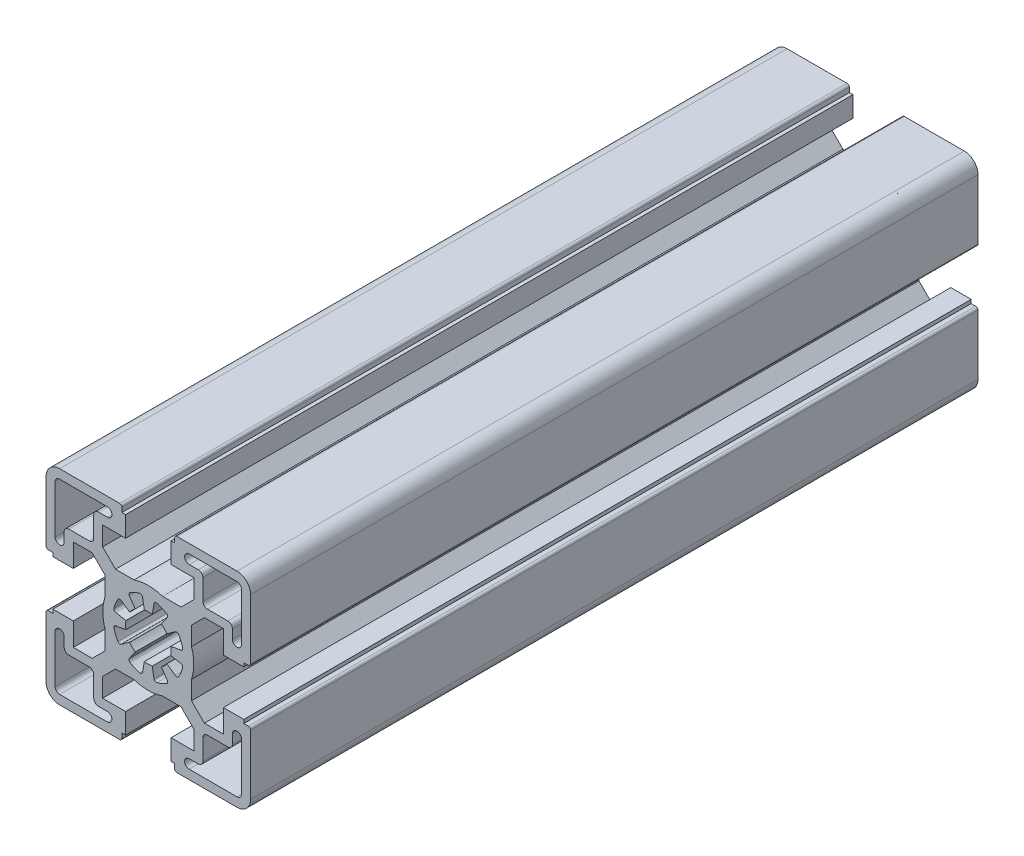
from build123d import *

# Parameters (mm, degrees)
BASE_EXTRUDE_DEPTH = 160


with BuildPart() as part:
    # Sketch1 → Base-Extrude (new body)
    with BuildSketch(Plane.XY):
        with BuildLine():
            Line((-4.99999574, -16.499883971), (-4.99999574, -20.99990968))
            Line((-4.99999574, -20.99990968), (-5.80004044, -20.99990968))
            Line((-5.80004044, -20.99990968), (-5.80004044, -21.999970054))
            ThreePointArc((-5.80004044, -21.999970054), (-5.946487232, -22.353523887), (-6.300041066, -22.49997068))
            Line((-6.300041066, -22.49997068), (-19.500014911, -22.49997068))
            ThreePointArc((-19.500014911, -22.49997068), (-21.62133367, -21.62129168), (-22.50001267, -19.499972921))
            Line((-22.50001267, -19.499972921), (-22.50001267, -6.299929564))
            ThreePointArc((-22.50001267, -6.299929564), (-22.353566213, -5.946376541), (-22.00001319, -5.799930084))
            Line((-22.00001319, -5.799930084), (-21.000012806, -5.799930084))
            Line((-21.000012806, -5.799930084), (-21.000012806, -4.999940084))
            Line((-21.000012806, -4.999940084), (-16.500012806, -4.999940084))
            Line((-16.500012806, -4.999940084), (-16.500012806, -10.049940084))
            Line((-16.500012806, -10.049940084), (-12.342923806, -10.049940084))
            Line((-12.342923806, -10.049940084), (-9.499953806, -7.206970084))
            Line((-9.499953806, -7.206970084), (-9.499953806, -3.122617084))
            ThreePointArc((-9.499953806, -3.122617084), (-10.000013376, 6.1916e-05), (-9.499953806, 3.122740916))
            Line((-9.499953806, 3.122740916), (-9.499953806, 7.206970084))
            Line((-9.499953806, 7.206970084), (-12.342923806, 10.049940084))
            Line((-12.342923806, 10.049940084), (-16.500012806, 10.049940084))
            Line((-16.500012806, 10.049940084), (-16.500012806, 4.999940084))
            Line((-16.500012806, 4.999940084), (-21.000012806, 4.999940084))
            Line((-21.000012806, 4.999940084), (-21.000012806, 5.799930084))
            Line((-21.000012806, 5.799930084), (-22.00001319, 5.799930084))
            ThreePointArc((-22.00001319, 5.799930084), (-22.353566213, 5.946376541), (-22.50001267, 6.299929564))
            Line((-22.50001267, 6.299929564), (-22.50001267, 19.499972921))
            ThreePointArc((-22.50001267, 19.499972921), (-21.62133367, 21.62129168), (-19.500014911, 22.49997068))
            Line((-19.500014911, 22.49997068), (-6.299954884, 22.49997068))
            ThreePointArc((-6.299954884, 22.49997068), (-5.946364566, 22.353508775), (-5.799902661, 21.999918456))
            Line((-5.799902661, 21.999918456), (-5.799902661, 20.999918083))
            Line((-5.799902661, 20.999918083), (-4.99999574, 20.999918083))
            Line((-4.99999574, 20.999918083), (-4.99999574, 16.499989166))
            Line((-4.99999574, 16.499989166), (-10.050086009, 16.499989166))
            Line((-10.050086009, 16.499989166), (-10.050086009, 12.342794971))
            Line((-10.050086009, 12.342794971), (-7.207151696, 9.499860659))
            Line((-7.207151696, 9.499860659), (-3.122798696, 9.499860659))
            ThreePointArc((-3.122798696, 9.499860659), (-0.000120196, 9.999920064), (3.122558304, 9.499860659))
            Line((3.122558304, 9.499860659), (7.206958901, 9.499860659))
            Line((7.206958901, 9.499860659), (10.049884116, 12.342787875))
            Line((10.049884116, 12.342787875), (10.049884116, 16.499989166))
            Line((10.049884116, 16.499989166), (4.99999574, 16.499989166))
            Line((4.99999574, 16.499989166), (4.99999574, 20.999963909))
            Line((4.99999574, 20.999963909), (5.799902661, 20.999963909))
            Line((5.799902661, 20.999963909), (5.799902661, 21.999918456))
            ThreePointArc((5.799902661, 21.999918456), (5.946364566, 22.353508775), (6.299954884, 22.49997068))
            Line((6.299954884, 22.49997068), (19.500081571, 22.49997068))
            ThreePointArc((19.500081571, 22.49997068), (21.62140033, 21.62129168), (22.50007933, 19.499972921))
            Line((22.50007933, 19.499972921), (22.50007933, 6.299877709))
            ThreePointArc((22.50007933, 6.299877709), (22.35363283, 5.946324583), (22.000079704, 5.799878083))
            Line((22.000079704, 5.799878083), (20.999995421, 5.799878083))
            Line((20.999995421, 5.799878083), (20.999995421, 4.999941084))
            Line((20.999995421, 4.999941084), (16.499983596, 4.999941084))
            Line((16.499983596, 4.999941084), (16.499983596, 10.049940084))
            Line((16.499983596, 10.049940084), (12.342894596, 10.049940084))
            Line((12.342894596, 10.049940084), (9.499922596, 7.206970084))
            Line((9.499922596, 7.206970084), (9.499922596, 3.122735916))
            ThreePointArc((9.499922596, 3.122735916), (9.999982165, 5.6916e-05), (9.499922596, -3.122622084))
            Line((9.499922596, -3.122622084), (9.499922596, -7.206970084))
            Line((9.499922596, -7.206970084), (12.342894596, -10.049940084))
            Line((12.342894596, -10.049940084), (16.499983596, -10.049940084))
            Line((16.499983596, -10.049940084), (16.499983596, -4.999941084))
            Line((16.499983596, -4.999941084), (20.999995421, -4.999941084))
            Line((20.999995421, -4.999941084), (20.999995421, -5.799878083))
            Line((20.999995421, -5.799878083), (22.000079704, -5.799878083))
            ThreePointArc((22.000079704, -5.799878083), (22.35363283, -5.946324583), (22.50007933, -6.299877709))
            Line((22.50007933, -6.299877709), (22.50007933, -19.499973421))
            ThreePointArc((22.50007933, -19.499973421), (21.621400476, -21.621291826), (19.500082071, -22.49997068))
            Line((19.500082071, -22.49997068), (6.300041066, -22.49997068))
            ThreePointArc((6.300041066, -22.49997068), (5.946487232, -22.353523887), (5.80004044, -21.999970054))
            Line((5.80004044, -21.999970054), (5.80004044, -20.99990968))
            Line((5.80004044, -20.99990968), (4.99999574, -20.99990968))
            Line((4.99999574, -20.99990968), (4.99999574, -16.499883971))
            Line((4.99999574, -16.499883971), (10.049884116, -16.499883971))
            Line((10.049884116, -16.499883971), (10.049884116, -12.342787875))
            Line((10.049884116, -12.342787875), (7.206933602, -9.49983536))
            Line((7.206933602, -9.49983536), (3.122579602, -9.49983536))
            ThreePointArc((3.122579602, -9.49983536), (-9.9398e-05, -9.99989493), (-3.122778398, -9.49983536))
            Line((-3.122778398, -9.49983536), (-7.207126398, -9.49983536))
            Line((-7.207126398, -9.49983536), (-10.050086009, -12.342794971))
            Line((-10.050086009, -12.342794971), (-10.050086009, -16.499883971))
            Line((-10.050086009, -16.499883971), (-4.99999574, -16.499883971))
        make_face()
        with BuildLine():
            Line((2.867879873, -4.095738521), (4.173655323, -5.960570749))
            ThreePointArc((4.173655323, -5.960570749), (4.253216568, -6.351019498), (4.022116912, -6.67563183))
            ThreePointArc((4.022116912, -6.67563183), (2.982522085, -7.200419904), (1.876337234, -7.564446005))
            ThreePointArc((1.876337234, -7.564446005), (1.483389354, -7.498323537), (1.263557864, -7.165976831))
            Line((1.263557864, -7.165976831), (0.868239441, -4.924019626))
            ThreePointArc((0.868239441, -4.924019626), (7.92e-06, -4.9999809), (-0.868223842, -4.924022376))
            Line((-0.868223842, -4.924022376), (-1.263535162, -7.165980833))
            ThreePointArc((-1.263535162, -7.165980833), (-1.483365599, -7.498328236), (-1.87631327, -7.564451949))
            ThreePointArc((-1.87631327, -7.564451949), (-2.982515957, -7.200422442), (-4.022126697, -6.675625934))
            ThreePointArc((-4.022126697, -6.675625934), (-4.253225878, -6.351013263), (-4.173664061, -5.960564631))
            Line((-4.173664061, -5.960564631), (-2.867885877, -4.095734317))
            ThreePointArc((-2.867885877, -4.095734317), (-3.535525782, -3.535515019), (-4.095743048, -2.867873408))
            Line((-4.095743048, -2.867873408), (-5.960577337, -4.173645915))
            ThreePointArc((-5.960577337, -4.173645915), (-6.351026211, -4.253206544), (-6.675638178, -4.022106375))
            ThreePointArc((-6.675638178, -4.022106375), (-7.200423154, -2.982514238), (-7.564447133, -1.876332686))
            ThreePointArc((-7.564447133, -1.876332686), (-7.498324428, -1.483384846), (-7.16597759, -1.263553556))
            Line((-7.16597759, -1.263553556), (-4.924020148, -0.868236481))
            ThreePointArc((-4.924020148, -0.868236481), (-4.9999809, 0), (-4.924020148, 0.868236481))
            Line((-4.924020148, 0.868236481), (-7.16597759, 1.263553556))
            ThreePointArc((-7.16597759, 1.263553556), (-7.498324428, 1.483384846), (-7.564447133, 1.876332686))
            ThreePointArc((-7.564447133, 1.876332686), (-7.200423154, 2.982514238), (-6.675638178, 4.022106375))
            ThreePointArc((-6.675638178, 4.022106375), (-6.351026211, 4.253206544), (-5.960577337, 4.173645915))
            Line((-5.960577337, 4.173645915), (-4.095743048, 2.867873408))
            ThreePointArc((-4.095743048, 2.867873408), (-3.535525782, 3.535515019), (-2.867885877, 4.095734317))
            Line((-2.867885877, 4.095734317), (-4.173664061, 5.960564631))
            ThreePointArc((-4.173664061, 5.960564631), (-4.253225878, 6.351013263), (-4.022126697, 6.675625934))
            ThreePointArc((-4.022126697, 6.675625934), (-2.982515957, 7.200422442), (-1.87631327, 7.564451949))
            ThreePointArc((-1.87631327, 7.564451949), (-1.483365599, 7.498328236), (-1.263535162, 7.165980833))
            Line((-1.263535162, 7.165980833), (-0.868223842, 4.924022376))
            ThreePointArc((-0.868223842, 4.924022376), (7.92e-06, 4.9999809), (0.868239441, 4.924019626))
            Line((0.868239441, 4.924019626), (1.263557864, 7.165976831))
            ThreePointArc((1.263557864, 7.165976831), (1.483389354, 7.498323537), (1.876337234, 7.564446005))
            ThreePointArc((1.876337234, 7.564446005), (2.982522085, 7.200419904), (4.022116912, 6.67563183))
            ThreePointArc((4.022116912, 6.67563183), (4.253216568, 6.351019498), (4.173655323, 5.960570749))
            Line((4.173655323, 5.960570749), (2.867879873, 4.095738521))
            ThreePointArc((2.867879873, 4.095738521), (3.535523556, 3.535517244), (4.095743641, 2.867872561))
            Line((4.095743641, 2.867872561), (5.9605782, 4.173644682))
            ThreePointArc((5.9605782, 4.173644682), (6.351027091, 4.25320523), (6.67563901, 4.022104994))
            ThreePointArc((6.67563901, 4.022104994), (7.200422982, 2.982514654), (7.564446528, 1.876335125))
            ThreePointArc((7.564446528, 1.876335125), (7.49832395, 1.483387263), (7.165977183, 1.263555866))
            Line((7.165977183, 1.263555866), (4.924019868, 0.868238068))
            ThreePointArc((4.924019868, 0.868238068), (4.9999809, 0), (4.924019868, -0.868238068))
            Line((4.924019868, -0.868238068), (7.165977183, -1.263555866))
            ThreePointArc((7.165977183, -1.263555866), (7.49832395, -1.483387263), (7.564446528, -1.876335125))
            ThreePointArc((7.564446528, -1.876335125), (7.200422982, -2.982514654), (6.67563901, -4.022104994))
            ThreePointArc((6.67563901, -4.022104994), (6.351027091, -4.25320523), (5.9605782, -4.173644682))
            Line((5.9605782, -4.173644682), (4.095743641, -2.867872561))
            ThreePointArc((4.095743641, -2.867872561), (3.535523556, -3.535517244), (2.867879873, -4.095738521))
        make_face(mode=Mode.SUBTRACT)
        with BuildLine():
            Line((-17.500118733, -12.000017917), (-13.000117238, -12.000017917))
            ThreePointArc((-13.000117238, -12.000017917), (-12.293010985, -12.292910917), (-12.000117985, -13.00001717))
            Line((-12.000117985, -13.00001717), (-12.000117985, -17.49992083))
            ThreePointArc((-12.000117985, -17.49992083), (-11.707224985, -18.207027083), (-11.000118733, -18.499920083))
            Line((-11.000118733, -18.499920083), (-9.000117985, -18.499920083))
            ThreePointArc((-9.000117985, -18.499920083), (-8.000069068, -19.499969), (-9.000117985, -20.500017917))
            Line((-9.000117985, -20.500017917), (-19.500118733, -20.500017917))
            ThreePointArc((-19.500118733, -20.500017917), (-20.207224985, -20.207124917), (-20.500117985, -19.500018664))
            Line((-20.500117985, -19.500018664), (-20.500117985, -8.999920083))
            ThreePointArc((-20.500117985, -8.999920083), (-19.500117985, -7.999920083), (-18.500117985, -8.999920083))
            Line((-18.500117985, -8.999920083), (-18.500117985, -11.000018664))
            ThreePointArc((-18.500117985, -11.000018664), (-18.207224985, -11.707124917), (-17.500118733, -12.000017917))
        make_face(mode=Mode.SUBTRACT)
        with BuildLine():
            Line((13.000003267, -12.000017917), (17.500004762, -12.000017917))
            ThreePointArc((17.500004762, -12.000017917), (18.207111015, -11.707124917), (18.500004015, -11.000018664))
            Line((18.500004015, -11.000018664), (18.500004015, -9.000115751))
            ThreePointArc((18.500004015, -9.000115751), (19.500004015, -8.000115751), (20.500004015, -9.000115751))
            Line((20.500004015, -9.000115751), (20.500004015, -19.500018664))
            ThreePointArc((20.500004015, -19.500018664), (20.207111015, -20.207124917), (19.500004762, -20.500017917))
            Line((19.500004762, -20.500017917), (9.000004015, -20.500017917))
            ThreePointArc((9.000004015, -20.500017917), (7.999955097, -19.499969), (9.000004015, -18.499920083))
            Line((9.000004015, -18.499920083), (11.000004762, -18.499920083))
            ThreePointArc((11.000004762, -18.499920083), (11.707111015, -18.207027083), (12.000004015, -17.49992083))
            Line((12.000004015, -17.49992083), (12.000004015, -13.00001717))
            ThreePointArc((12.000004015, -13.00001717), (12.292897015, -12.292910917), (13.000003267, -12.000017917))
        make_face(mode=Mode.SUBTRACT)
        with BuildLine():
            Line((-17.500118733, 12.000017917), (-13.000117238, 12.000017917))
            ThreePointArc((-13.000117238, 12.000017917), (-12.293010985, 12.292910917), (-12.000117985, 13.00001717))
            Line((-12.000117985, 13.00001717), (-12.000117985, 17.49992083))
            ThreePointArc((-12.000117985, 17.49992083), (-11.707224985, 18.207027083), (-11.000118733, 18.499920083))
            Line((-11.000118733, 18.499920083), (-9.000117985, 18.499920083))
            ThreePointArc((-9.000117985, 18.499920083), (-8.000069068, 19.499969), (-9.000117985, 20.500017917))
            Line((-9.000117985, 20.500017917), (-19.500118733, 20.500017917))
            ThreePointArc((-19.500118733, 20.500017917), (-20.207224985, 20.207124917), (-20.500117985, 19.500018664))
            Line((-20.500117985, 19.500018664), (-20.500117985, 8.999920083))
            ThreePointArc((-20.500117985, 8.999920083), (-19.500117985, 7.999920083), (-18.500117985, 8.999920083))
            Line((-18.500117985, 8.999920083), (-18.500117985, 11.000018664))
            ThreePointArc((-18.500117985, 11.000018664), (-18.207224985, 11.707124917), (-17.500118733, 12.000017917))
        make_face(mode=Mode.SUBTRACT)
        with BuildLine():
            Line((13.000003267, 12.000017917), (17.500004762, 12.000017917))
            ThreePointArc((17.500004762, 12.000017917), (18.207111015, 11.707124917), (18.500004015, 11.000018664))
            Line((18.500004015, 11.000018664), (18.500004015, 9.000115751))
            ThreePointArc((18.500004015, 9.000115751), (19.500004015, 8.000115751), (20.500004015, 9.000115751))
            Line((20.500004015, 9.000115751), (20.500004015, 19.500018664))
            ThreePointArc((20.500004015, 19.500018664), (20.207111015, 20.207124917), (19.500004762, 20.500017917))
            Line((19.500004762, 20.500017917), (9.000004015, 20.500017917))
            ThreePointArc((9.000004015, 20.500017917), (7.999955097, 19.499969), (9.000004015, 18.499920083))
            Line((9.000004015, 18.499920083), (11.000004762, 18.499920083))
            ThreePointArc((11.000004762, 18.499920083), (11.707111015, 18.207027083), (12.000004015, 17.49992083))
            Line((12.000004015, 17.49992083), (12.000004015, 13.00001717))
            ThreePointArc((12.000004015, 13.00001717), (12.292897015, 12.292910917), (13.000003267, 12.000017917))
        make_face(mode=Mode.SUBTRACT)
    extrude(amount=BASE_EXTRUDE_DEPTH)


solid = part.part
